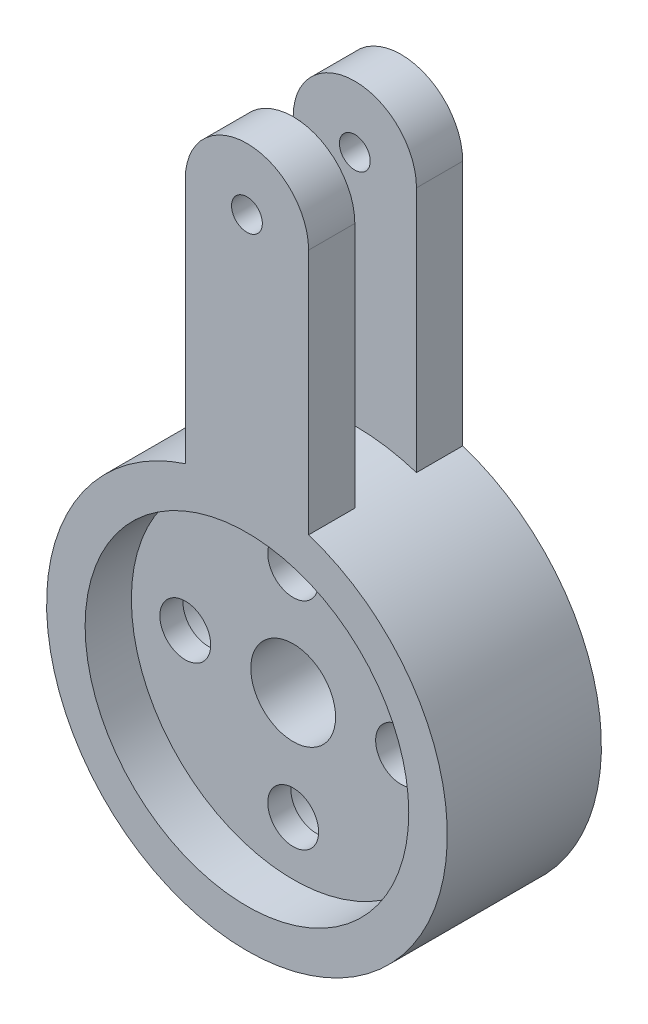
from build123d import *

# Parameters (mm, degrees)
ESQUISSE1_R             = 13
ESQUISSE1_R_2           = 2.75
ESQUISSE1_R_3           = 1.65
BOSS_EXTRU_1_DEPTH      = 10
ESQUISSE2_R             = 10.5
ENL_V_MAT_EXTRU_1_DEPTH = 3
ESQUISSE3_R             = 2.75
ENL_V_MAT_EXTRU_2_DEPTH = 5.5
ESQUISSE4_R             = 1
BOSS_EXTRU_2_DEPTH      = 3


with BuildPart() as part:
    # Esquisse1 → Boss.-Extru.1 (new body)
    with BuildSketch(Plane.XY):
        Circle(ESQUISSE1_R)
        Circle(ESQUISSE1_R_2, mode=Mode.SUBTRACT)
        with Locations((-7, 0)):
            Circle(ESQUISSE1_R_3, mode=Mode.SUBTRACT)
        with Locations((0, 7)):
            Circle(ESQUISSE1_R_3, mode=Mode.SUBTRACT)
        with Locations((7, 0)):
            Circle(ESQUISSE1_R_3, mode=Mode.SUBTRACT)
        with Locations((0, -7)):
            Circle(ESQUISSE1_R_3, mode=Mode.SUBTRACT)
    extrude(amount=BOSS_EXTRU_1_DEPTH)

    # Esquisse2 → Enlèv. mat.-Extru.1 (cut)
    with BuildSketch(Plane.XY.offset(10)):
        Circle(ESQUISSE2_R)
    extrude(amount=-ENL_V_MAT_EXTRU_1_DEPTH, mode=Mode.SUBTRACT)

    # Esquisse3 → Enlèv. mat.-Extru.2 (cut)
    with BuildSketch(Plane(origin=(0, 0, 0), x_dir=(-1, 0, 0), z_dir=(0, 0, -1))):
        with Locations((-7, 0)):
            Circle(ESQUISSE3_R)
        with Locations((0, 7)):
            Circle(ESQUISSE3_R)
        with Locations((7, 0)):
            Circle(ESQUISSE3_R)
        with Locations((0, -7)):
            Circle(ESQUISSE3_R)
    extrude(amount=-ENL_V_MAT_EXTRU_2_DEPTH, mode=Mode.SUBTRACT)

    # Esquisse4 → Boss.-Extru.2 (add)
    with BuildSketch(Plane(origin=(0, 0, 0), x_dir=(-1, 0, 0), z_dir=(0, 0, -1))):
        with BuildLine():
            Line((-4, 28.369316877), (-4, 12.369316877))
            ThreePointArc((-4, 12.369316877), (0, 13), (4, 12.369316877))
            Line((4, 12.369316877), (4, 28.369316877))
            ThreePointArc((4, 28.369316877), (0, 32.369316877), (-4, 28.369316877))
        make_face()
        with Locations((0, 28.369316877)):
            Circle(ESQUISSE4_R, mode=Mode.SUBTRACT)
    boss_extru_2 = extrude(amount=-BOSS_EXTRU_2_DEPTH)

    # Symétrie1: Boss.-Extru.2 across plane
    add(boss_extru_2.mirror(Plane.XY.offset(5)))


solid = part.part
